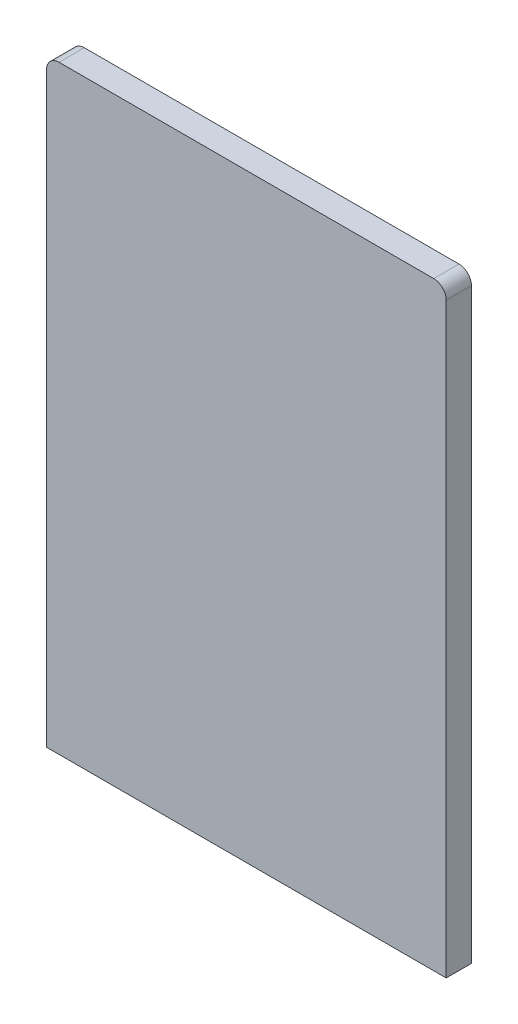
from build123d import *

# Parameters (mm, degrees)
SKETCH1_W           = 1.25
SKETCH1_H           = 4
BOSS_EXTRUDE1_DEPTH = 0.105
FILLET1_R           = 0.25
BOSS_EXTRUDE2_DEPTH = 0.2
BOSS_EXTRUDE3_DEPTH = 0.2


with BuildPart() as part:
    # Sketch1 → Boss-Extrude1 (new body)
    with BuildSketch(Plane.XY):
        with Locations((3.375, -6)):
            Rectangle(SKETCH1_W, SKETCH1_H)
        Polygon((-2.75, -4), (-2.75, -2.75), (-2.75, 2.75), (2.75, 2.75), (2.75, -2.75), (2.75, -4), (4, -4), (4, 4), (-4, 4), (-4, -4), align=None)
        with Locations((-3.375, -6)):
            Rectangle(SKETCH1_W, SKETCH1_H)
    extrude(amount=BOSS_EXTRUDE1_DEPTH)

    # Fillet1
    fillet1_edges = [part.edges().sort_by_distance(p)[0] for p in [
        (2.75, 2.75, 0.0525),
        (-2.75, 2.75, 0.0525),
        (-4, 4, 0.0525),
        (4, 4, 0.0525),
    ]]
    fillet(fillet1_edges, radius=FILLET1_R)

    # Sketch2 → Boss-Extrude2 (add)
    with BuildSketch(Plane(origin=(0, 0, 0), x_dir=(-1, 0, 0), z_dir=(0, 0, -1))):
        with BuildLine():
            Line((2.75, -8), (4, -8))
            Line((4, -8), (4, 3.75))
            ThreePointArc((4, 3.75), (3.926776695, 3.926776695), (3.75, 4))
            Line((3.75, 4), (-3.75, 4))
            ThreePointArc((-3.75, 4), (-3.926776695, 3.926776695), (-4, 3.75))
            Line((-4, 3.75), (-4, -8))
            Line((-4, -8), (-2.75, -8))
            Line((-2.75, -8), (-2.75, 2.5))
            ThreePointArc((-2.75, 2.5), (-2.676776695, 2.676776695), (-2.5, 2.75))
            Line((-2.5, 2.75), (2.5, 2.75))
            ThreePointArc((2.5, 2.75), (2.676776695, 2.676776695), (2.75, 2.5))
            Line((2.75, 2.5), (2.75, -8))
        make_face()
        with BuildLine():
            Line((-2.75, -8), (2.75, -8))
            Line((2.75, -8), (2.75, 2.5))
            ThreePointArc((2.75, 2.5), (2.676776695, 2.676776695), (2.5, 2.75))
            Line((2.5, 2.75), (-2.5, 2.75))
            ThreePointArc((-2.5, 2.75), (-2.676776695, 2.676776695), (-2.75, 2.5))
            Line((-2.75, 2.5), (-2.75, -8))
        make_face()
    extrude(amount=BOSS_EXTRUDE2_DEPTH)

    # Sketch4 → Boss-Extrude3 (add)
    with BuildSketch(Plane.XY.offset(0.105)):
        with BuildLine():
            ThreePointArc((4, 3.75), (3.926776695, 3.926776695), (3.75, 4))
            Line((3.75, 4), (-3.75, 4))
            ThreePointArc((-3.75, 4), (-3.926776695, 3.926776695), (-4, 3.75))
            Line((-4, 3.75), (-4, -8))
            Line((-4, -8), (-2.75, -8))
            Line((-2.75, -8), (-2.75, 2.5))
            ThreePointArc((-2.75, 2.5), (-2.676776695, 2.676776695), (-2.5, 2.75))
            Line((-2.5, 2.75), (2.5, 2.75))
            ThreePointArc((2.5, 2.75), (2.676776695, 2.676776695), (2.75, 2.5))
            Line((2.75, 2.5), (2.75, -8))
            Line((2.75, -8), (4, -8))
            Line((4, -8), (4, 3.75))
        make_face()
        with BuildLine():
            Line((-2.75, -8), (2.75, -8))
            Line((2.75, -8), (2.75, 2.5))
            ThreePointArc((2.75, 2.5), (2.676776695, 2.676776695), (2.5, 2.75))
            Line((2.5, 2.75), (-2.5, 2.75))
            ThreePointArc((-2.5, 2.75), (-2.676776695, 2.676776695), (-2.75, 2.5))
            Line((-2.75, 2.5), (-2.75, -8))
        make_face()
    extrude(amount=BOSS_EXTRUDE3_DEPTH)


solid = part.part
